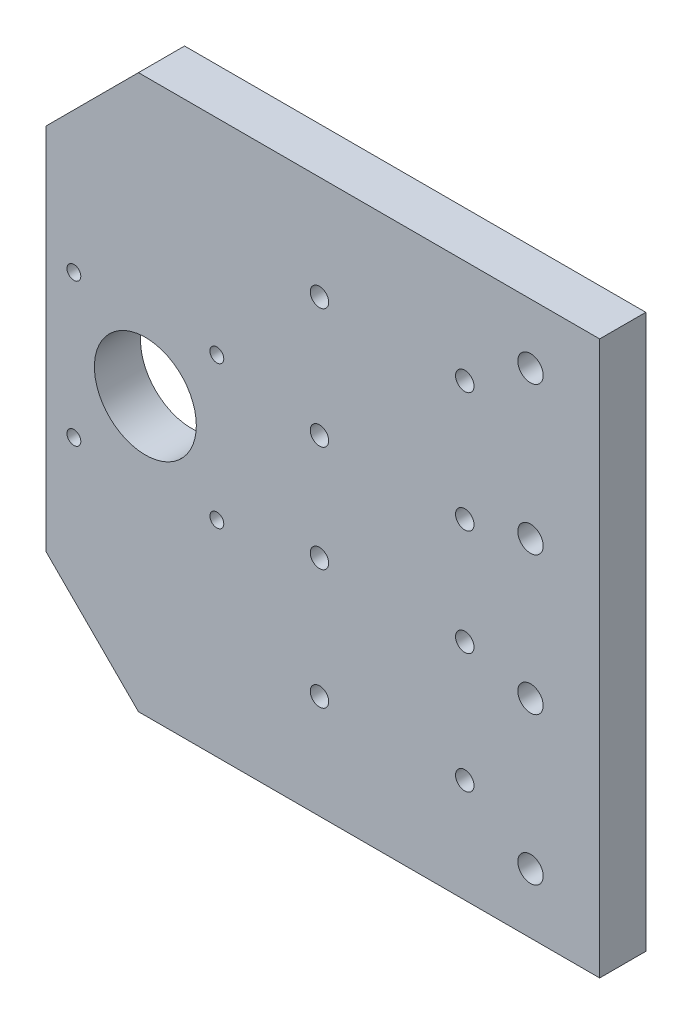
from build123d import *

# Parameters (mm, degrees)
SKETCH1_R           = 11.05
SKETCH1_R_2         = 1.5
SKETCH1_R_3         = 2
SKETCH1_R_4         = 2.75
BOSS_EXTRUDE1_DEPTH = 10


with BuildPart() as part:
    # Sketch1 → Boss-Extrude1 (new body)
    with BuildSketch(Plane.XY):
        Polygon((0, -60), (0, 60), (-100, 60), (-120, 40), (-120, -40), (-100, -60), align=None)
        with Locations((-98.5, 0)):
            Circle(SKETCH1_R, mode=Mode.SUBTRACT)
        with Locations((-83, 15.5)):
            Circle(SKETCH1_R_2, mode=Mode.SUBTRACT)
        with Locations((-114, 15.5)):
            Circle(SKETCH1_R_2, mode=Mode.SUBTRACT)
        with Locations((-114, -15.5)):
            Circle(SKETCH1_R_2, mode=Mode.SUBTRACT)
        with Locations((-83, -15.5)):
            Circle(SKETCH1_R_2, mode=Mode.SUBTRACT)
        with Locations((-60.75, 37.5)):
            Circle(SKETCH1_R_3, mode=Mode.SUBTRACT)
        with Locations((-29.25, 37.5)):
            Circle(SKETCH1_R_3, mode=Mode.SUBTRACT)
        with Locations((-60.75, 11.5)):
            Circle(SKETCH1_R_3, mode=Mode.SUBTRACT)
        with Locations((-29.25, 11.5)):
            Circle(SKETCH1_R_3, mode=Mode.SUBTRACT)
        with Locations((-60.75, -11.5)):
            Circle(SKETCH1_R_3, mode=Mode.SUBTRACT)
        with Locations((-29.25, -11.5)):
            Circle(SKETCH1_R_3, mode=Mode.SUBTRACT)
        with Locations((-29.25, -37.5)):
            Circle(SKETCH1_R_3, mode=Mode.SUBTRACT)
        with Locations((-60.75, -37.5)):
            Circle(SKETCH1_R_3, mode=Mode.SUBTRACT)
        with Locations((-15, 47)):
            Circle(SKETCH1_R_4, mode=Mode.SUBTRACT)
        with Locations((-15, 15)):
            Circle(SKETCH1_R_4, mode=Mode.SUBTRACT)
        with Locations((-15, -15)):
            Circle(SKETCH1_R_4, mode=Mode.SUBTRACT)
        with Locations((-15, -47)):
            Circle(SKETCH1_R_4, mode=Mode.SUBTRACT)
    extrude(amount=BOSS_EXTRUDE1_DEPTH)


solid = part.part
